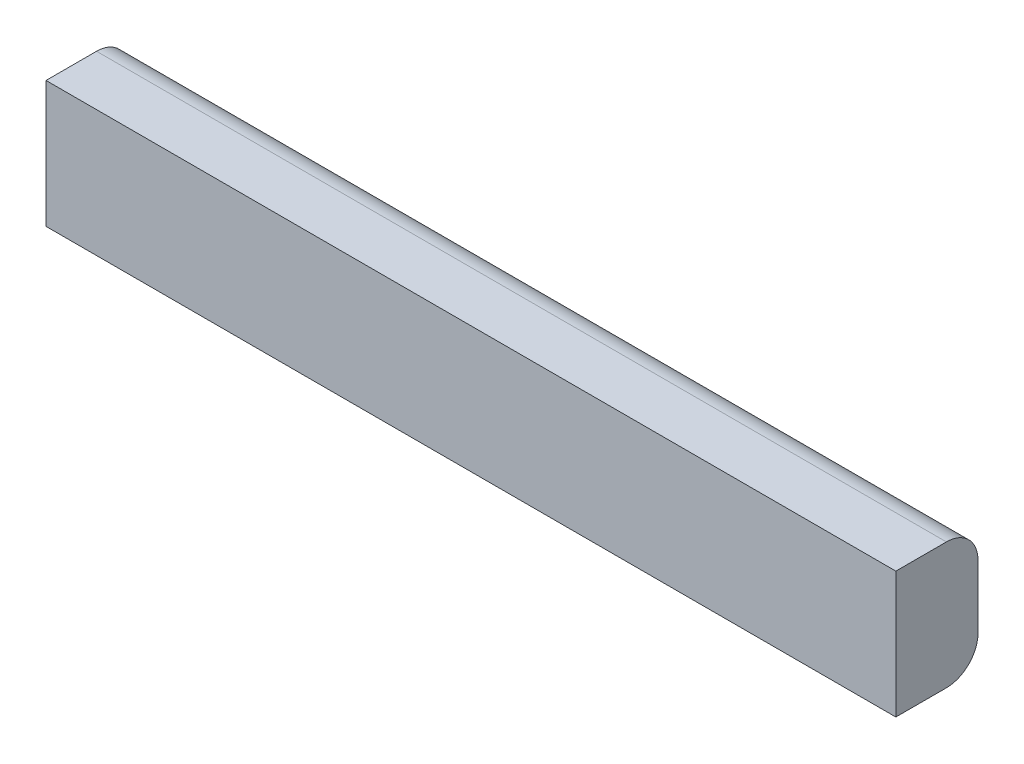
from build123d import *

# Parameters (mm, degrees)
BOSS_EXTRUDE1_DEPTH = 426.974


with BuildPart() as part:
    # Sketch1 → Boss-Extrude1 (new body, symmetric)
    with BuildSketch(Plane(origin=(0, 0, 0), x_dir=(0, 0, -1), z_dir=(1, 0, 0))):
        with BuildLine():
            Line((49.373646209, 66.02166065), (-1.426353791, 66.02166065))
            Line((-1.426353791, 66.02166065), (-1.426353791, -60.97833935))
            Line((-1.426353791, -60.97833935), (49.373646209, -60.97833935))
            ThreePointArc((49.373646209, -60.97833935), (71.824286512, -51.678979653), (81.123646209, -29.22833935))
            Line((81.123646209, -29.22833935), (81.123646209, 34.27166065))
            ThreePointArc((81.123646209, 34.27166065), (71.824286512, 56.722300952), (49.373646209, 66.02166065))
        make_face()
    extrude(amount=BOSS_EXTRUDE1_DEPTH, both=True)


solid = part.part
